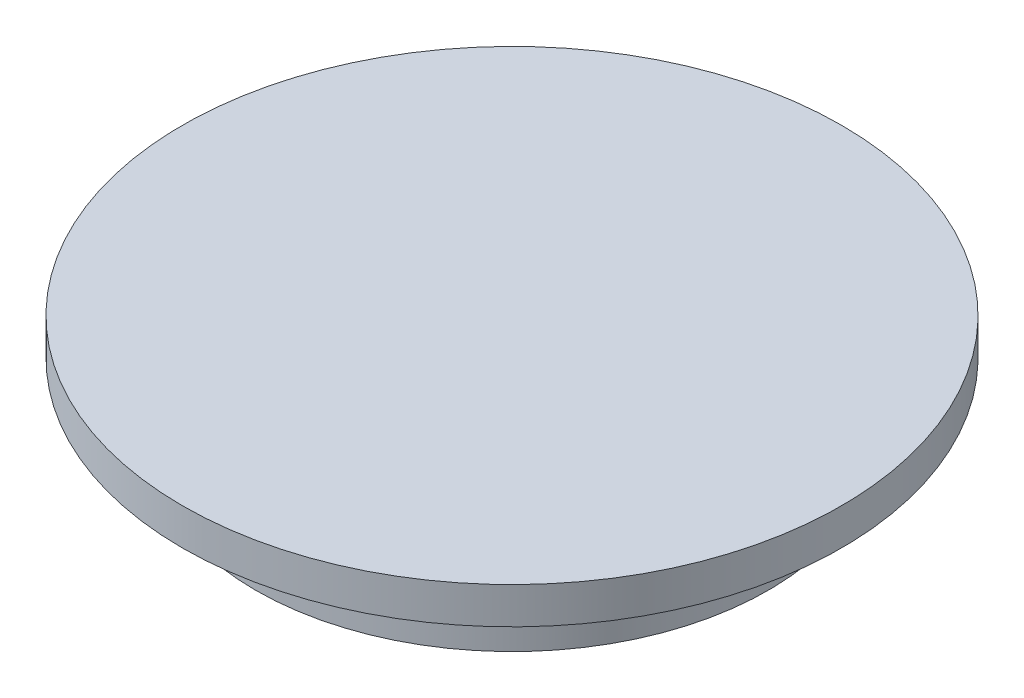
from build123d import *

# Parameters (mm, degrees)
SKETCH1_R           = 17.5
BOSS_EXTRUDE1_DEPTH = 5
SKETCH2_R           = 22.5
BOSS_EXTRUDE2_DEPTH = 2.5


with BuildPart() as part:
    # Sketch1 → Boss-Extrude1 (new body)
    with BuildSketch(Plane(origin=(0, 0, 0), x_dir=(1, 0, 0), z_dir=(0, 1, 0))):
        Circle(SKETCH1_R)
    extrude(amount=BOSS_EXTRUDE1_DEPTH)

    # Sketch2 → Boss-Extrude2 (add)
    with BuildSketch(Plane(origin=(0, 5, 0), x_dir=(1, 0, 0), z_dir=(0, 1, 0))):
        Circle(SKETCH2_R)
    extrude(amount=BOSS_EXTRUDE2_DEPTH)


solid = part.part
